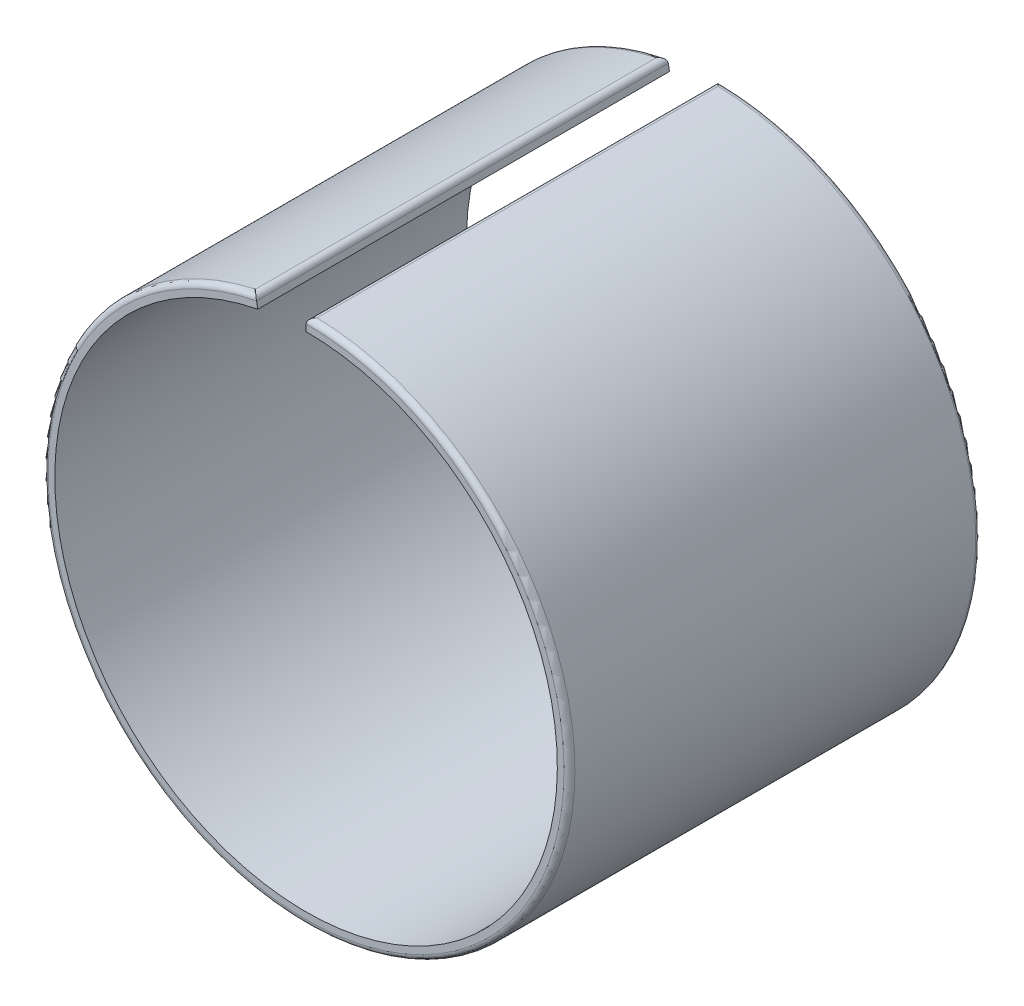
from build123d import *

# Parameters (mm, degrees)
BOSS_EXTRUDE3_DEPTH = 34
FILLET2_R           = 0.45


with BuildPart() as part:
    # Sketch4 → Boss-Extrude3 (new body)
    with BuildSketch(Plane.XY):
        with BuildLine():
            Line((0, 20.75), (0, 21.75))
            ThreePointArc((0, 21.75), (2.096385542, -21.648733627), (-4.173249856, 21.345877486))
            Line((-4.173249856, 21.345877486), (-3.981376299, 20.364457831))
            ThreePointArc((-3.981376299, 20.364457831), (2, -20.653389552), (0, 20.75))
        make_face()
    extrude(amount=BOSS_EXTRUDE3_DEPTH)

    # Fillet2
    fillet2_edges = [part.edges().sort_by_distance(p)[0] for p in [
        (2.096385542, -21.648733627, 34),
        (2.096385542, -21.648733627, 0),
        (0, 21.75, 17),
        (-4.173249856, 21.345877486, 17),
    ]]
    fillet(fillet2_edges, radius=FILLET2_R)


solid = part.part
